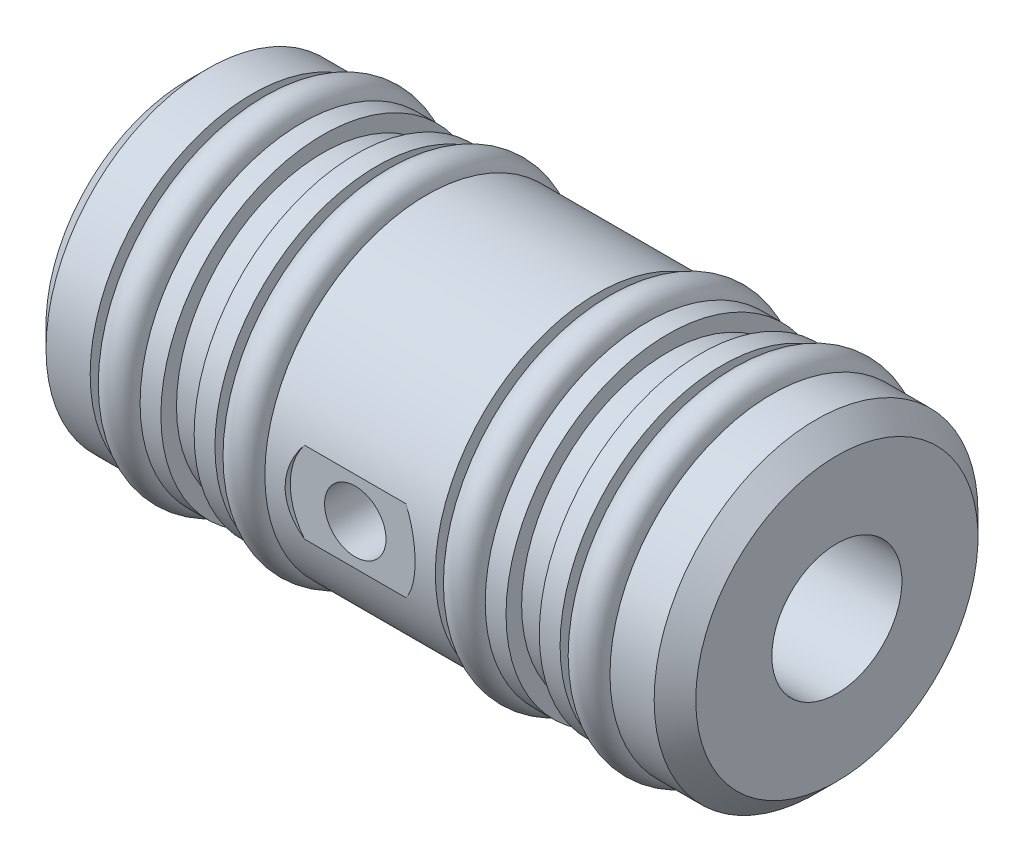
from build123d import *

# Parameters (mm, degrees)
CHAMFER1_SIZE                   = 1.016
F_1_4_0_25_DIAMETER_HOLE1_D     = 6.35
F_1_4_0_25_DIAMETER_HOLE1_DEPTH = 0.254
AIR_HOLE_D                      = 2.4892
AIR_HOLE_DEPTH                  = 6.35
AIR_HOLE_CBORE_D                = 3
AIR_HOLE_CBORE_DEPTH            = 6.096
AIR_HOLE_TIP                    = 0.747831126
SKETCH5_R                       = 0.85852


with BuildPart() as part:
    # Sketch1 → Revolve1 (revolve)
    with BuildSketch(Plane.XY, mode=Mode.PRIVATE) as revolve1_sk:
        Polygon((0, 3.17754), (31.75, 3.17754), (31.75, 7.9121), (28.575, 7.9121), (28.575, 6.6675), (26.1366, 6.6675), (26.1366, 7.9121), (25.1206, 7.9121), (25.1206, 7.1501), (23.495, 7.1501), (23.495, 7.9121), (22.479, 7.9121), (22.479, 6.6675), (20.0406, 6.6675), (20.0406, 7.9121), (11.7094, 7.9121), (11.7094, 6.6675), (9.271, 6.6675), (9.271, 7.9121), (8.255, 7.9121), (8.255, 7.1501), (6.6294, 7.1501), (6.6294, 7.9121), (5.6134, 7.9121), (5.6134, 6.6675), (3.175, 6.6675), (3.175, 7.9121), (0, 7.9121), align=None)
    revolve(revolve1_sk.sketch.rotate(Axis((0, 0, 0), (1, 0, 0)), 90), axis=Axis((0, 0, 0), (1, 0, 0)))  # turned: the seam where the file's is

    # Chamfer1
    chamfer1_edges = [part.edges().sort_by_distance(p)[0] for p in [
        (31.75, 0, -7.9121),
        (0, 0, -7.9121),
    ]]
    chamfer(chamfer1_edges, length=CHAMFER1_SIZE)

    # 1/4 (0.25) Diameter Hole1
    with Locations(Plane(origin=(15.875, 0, 7.9121), x_dir=(1, 0, 0), z_dir=(0, 0, 1))):
        with Locations((0, 0)):
            Hole(F_1_4_0_25_DIAMETER_HOLE1_D / 2, depth=F_1_4_0_25_DIAMETER_HOLE1_DEPTH)

    # Air Hole
    with Locations(Plane.XY.offset(7.6581)):
        with Locations((15.875, 0)):
            CounterBoreHole(AIR_HOLE_D / 2, AIR_HOLE_CBORE_D / 2, AIR_HOLE_CBORE_DEPTH, depth=AIR_HOLE_DEPTH)
            with Locations((0, 0, -(AIR_HOLE_DEPTH + AIR_HOLE_TIP / 2))):  # 118° drill point
                Cone(0, AIR_HOLE_D / 2, AIR_HOLE_TIP, mode=Mode.SUBTRACT)

    # Sketch5 → Revolve2 (revolve)
    with BuildSketch(Plane.XY, mode=Mode.PRIVATE) as revolve2_sk:
        with Locations((27.3566, 7.52348)):
            Circle(SKETCH5_R)
        with Locations((21.2606, 7.52348)):
            Circle(SKETCH5_R)
        with Locations((10.4894, 7.52348)):
            Circle(SKETCH5_R)
        with Locations((4.3942, 7.52348)):
            Circle(SKETCH5_R)
    revolve(revolve2_sk.sketch.rotate(Axis((0, 0, 0), (1, 0, 0)), 90), axis=Axis((0, 0, 0), (1, 0, 0)))  # turned: the seam where the file's is


solid = part.part
